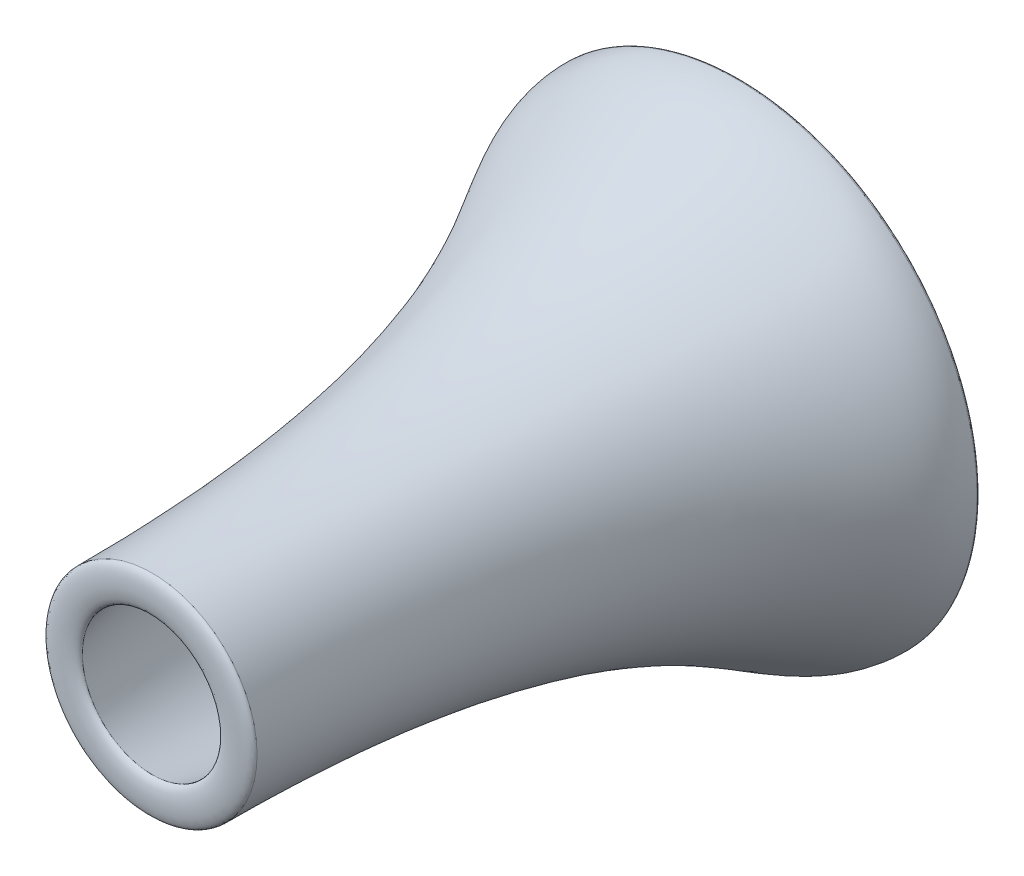
from build123d import *


with BuildPart() as part:
    # Sketch21 → Revolve2 (revolve)
    with BuildSketch(Plane(origin=(0, 0, 0), x_dir=(1, 0, 0), z_dir=(0, 1, 0))):
        with BuildLine():
            Line((-110.643738414, -1094.654678065), (-166.463971853, -1094.654678065))
            add(Edge.make_bspline(
                [(-381.249942517, -167.561077714), (-381.249942517, -292.94503009), (-166.463971853, -364.34555768), (-166.463971853, -1094.654678065)],
                knots=[0, 0, 0, 0, 1, 1, 1, 1], degree=3))
            Line((-381.249942517, -167.561077714), (-259.495458194, -167.561077714))
            add(Edge.make_bspline(
                [(-259.495458194, -167.561077714), (-243.481208412, -195.194577557), (-128.674034214, -903.320051911), (-183.485035369, -717.331180747), (-110.643738414, -1094.654678065)],
                knots=[0, 0, 0, 0, 0.206506907, 1, 1, 1, 1], degree=3))
        make_face()
    revolve(axis=Axis((0, 0, 99.684784321), (0, 0, -1)))


with BuildPart() as body_2:
    # Sketch22 → Revolve3 (revolve)
    with BuildSketch(Plane(origin=(0, 0, 0), x_dir=(1, 0, 0), z_dir=(0, 1, 0))):
        with BuildLine():
            Line((-381.249942517, -167.561077714), (-259.495458194, -167.561077714))
            add(Edge.make_bspline(
                [(-381.249942517, -167.561077714), (-381.249942517, -150.62774438), (-259.495458194, -150.62774438), (-259.495458194, -167.561077714)],
                knots=[0, 0, 0, 0, 1, 1, 1, 1], degree=3))
        make_face()
    revolve(axis=Axis((0, 0, 99.684784321), (0, 0, -1)))


with BuildPart() as body_3:
    # Sketch23 → Revolve4 (revolve)
    with BuildSketch(Plane(origin=(0, 0, 0), x_dir=(1, 0, 0), z_dir=(0, 1, 0))):
        with BuildLine():
            Line((-166.463971853, -1094.654678065), (-110.643738414, -1094.654678065))
            add(Edge.make_bspline(
                [(-166.463971853, -1094.654678065), (-166.463971853, -1107.354678065), (-110.643738414, -1107.354678065), (-110.643738414, -1094.654678065)],
                knots=[0, 0, 0, 0, 1, 1, 1, 1], degree=3))
        make_face()
    revolve(axis=Axis((0, 0, 1104.756830123), (0, 0, -1)))


solid = Compound([part.part, body_2.part, body_3.part])
